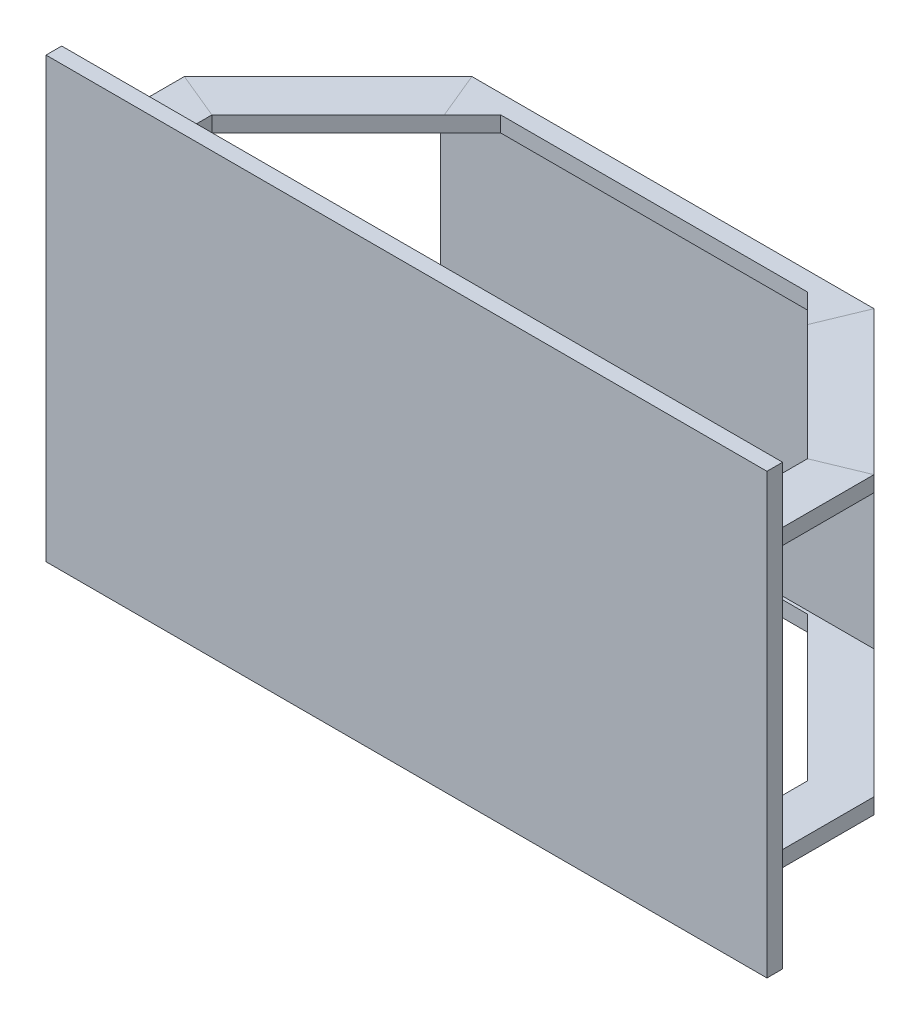
from build123d import *

# Parameters (mm, degrees)
SKETCH1_W           = 230
SKETCH1_H           = 140
BOSS_EXTRUDE1_DEPTH = 5
SKETCH4_W           = 15
SKETCH4_H           = 94
CUT_EXTRUDE1_DEPTH  = 118
SKETCH7_W           = 72
SKETCH7_H           = 84
CUT_EXTRUDE2_DEPTH  = 226


with BuildPart() as part:
    # Sketch1 → Boss-Extrude1 (new body)
    with BuildSketch(Plane.XY):
        Rectangle(SKETCH1_W, SKETCH1_H)
    extrude(amount=BOSS_EXTRUDE1_DEPTH)

    # Sweep3: sweep along a path in Sketch5
    with BuildLine(Plane(origin=(0, 0, 0), x_dir=(1, 0, 0), z_dir=(0, 1, 0))) as sweep3_path:
        Line((-100, 0), (-100, 30))
        Line((-100, 30), (-60, 70))
        Line((-60, 70), (60, 70))
        Line((60, 70), (100, 30))
        Line((100, 30), (100, 0))
    # Sketch4 → Sweep3 (sweep)
    with BuildSketch(Plane.XY):
        with Locations((-102.5, 0)):
            Rectangle(SKETCH4_W, SKETCH4_H)
    sweep(path=sweep3_path.line, transition=Transition.RIGHT)

    # Sketch6 → Cut-Extrude1 (cut, through all)
    with BuildSketch(Plane(origin=(0, 47, 0), x_dir=(1, 0, 0), z_dir=(0, 1, 0))):
        Polygon((-48.928932188, 74), (48.928932188, 74), (76.464466094, 46.464466094), (-76.464466094, 46.464466094), align=None)
    extrude(amount=-CUT_EXTRUDE1_DEPTH, mode=Mode.SUBTRACT)

    # Sketch7 → Cut-Extrude2 (cut, through all)
    with BuildSketch(Plane.ZY.offset(110)):
        with Locations((-39, 0)):
            Rectangle(SKETCH7_W, SKETCH7_H)
    extrude(amount=-CUT_EXTRUDE2_DEPTH, mode=Mode.SUBTRACT)


solid = part.part
